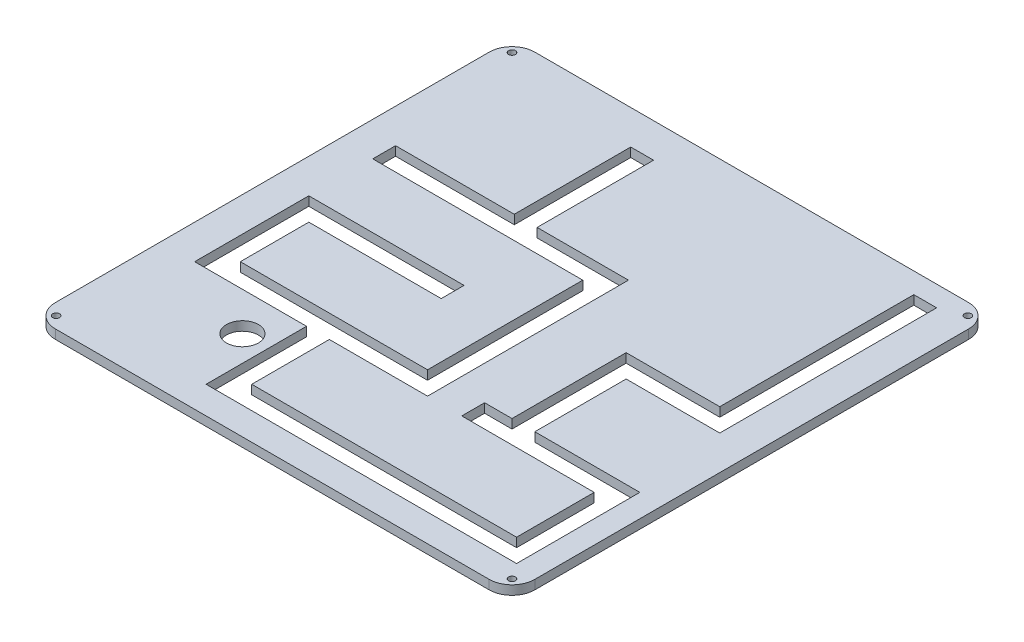
from build123d import *

# Parameters (mm, degrees)
SKETCH1_W         = 210
SKETCH1_H         = 210
MAINEXTRUDE_DEPTH = 4
SKETCH1_6_R       = 1.5
SCREWHOLES_DEPTH  = 4
ROUNDEDCORNERS_R  = 10
SKETCH3_R         = 7
TRENCH_DEPTH      = 4


with BuildPart() as part:
    # Sketch1 → MainExtrude (new body)
    with BuildSketch(Plane(origin=(0, 0, 0), x_dir=(1, 0, 0), z_dir=(0, 1, 0))):
        Rectangle(SKETCH1_W, SKETCH1_H)
    extrude(amount=MAINEXTRUDE_DEPTH)

    # Sketch1_6 → ScrewHoles (cut)
    with BuildSketch(Plane(origin=(0, 0, 0), x_dir=(1, 0, 0), z_dir=(0, 1, 0))):
        with Locations((-99.833273811, 99.833273811)):
            Circle(SKETCH1_6_R)
        with Locations((-99.833273811, -99.833273811)):
            Circle(SKETCH1_6_R)
        with Locations((99.833273811, -99.833273811)):
            Circle(SKETCH1_6_R)
        with Locations((99.833273811, 99.833273811)):
            Circle(SKETCH1_6_R)
    extrude(amount=SCREWHOLES_DEPTH, mode=Mode.SUBTRACT)

    # RoundedCorners
    roundedcorners_edges = [part.edges().sort_by_distance(p)[0] for p in [
        (-105, 2, -105),
        (-105, 2, 105),
        (105, 2, 105),
        (105, 2, -105),
    ]]
    fillet(roundedcorners_edges, radius=ROUNDEDCORNERS_R)

    # Sketch3 → Trench (cut)
    with BuildSketch(Plane(origin=(0, 0, 0), x_dir=(1, 0, 0), z_dir=(0, 1, 0))):
        with Locations((-52.205723714, -65.868416485)):
            Circle(SKETCH3_R)
        Polygon((-38, 90), (-38, 39), (-90, 39), (-90, 29), (2, 29), (2, -39), (-80, -39), (-80, -9), (-22, -9), (-22, 1), (-90, 1), (-90, -49), (-41, -49), (-41, -93), (95, -93), (95, -39), (49, -39), (49, 1), (90, 1), (90, 96), (80, 96), (80, 11), (39, 11), (39, -39), (27, -39), (27, -49), (85, -49), (85, -83), (-31, -83), (-31, -49), (12, -49), (12, 39), (-28, 39), (-28, 90), align=None)
    extrude(amount=TRENCH_DEPTH, mode=Mode.SUBTRACT)


solid = part.part
